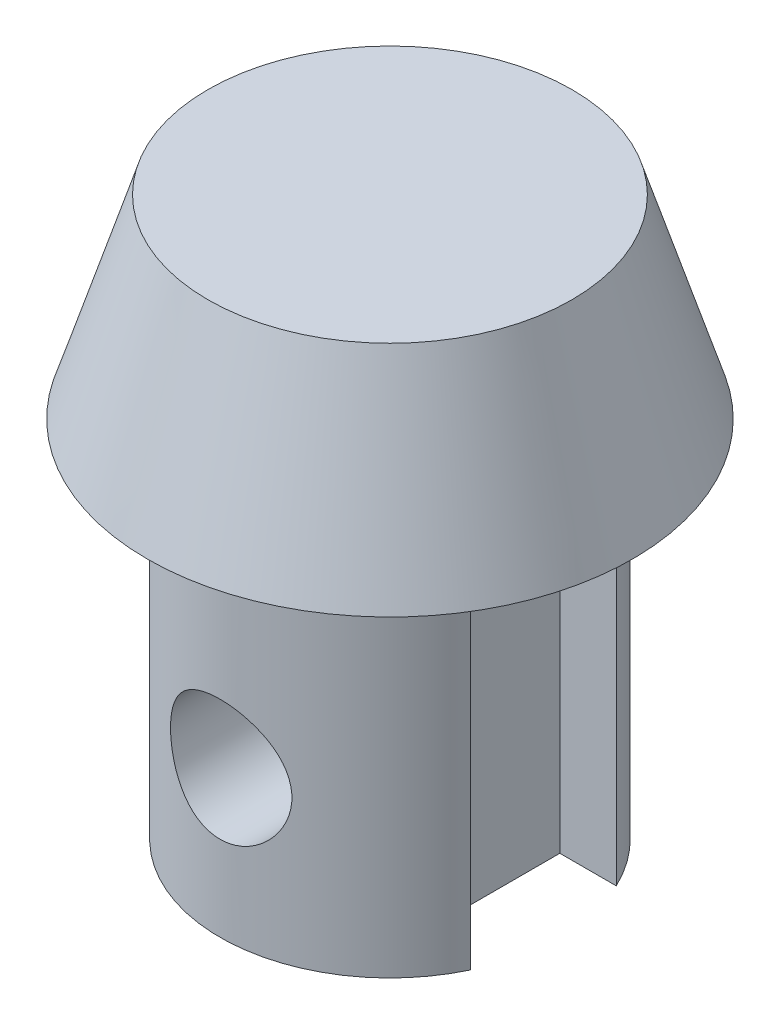
from build123d import *

# Parameters (mm, degrees)
BOSS_EXTRUDE1_DEPTH     = 15
SKETCH3_R               = 7.5
SKETCH2_R               = 10
SKETCH4_R               = 2.5
CUT_EXTRUDE1_DEPTH      = 22.0000001
CUT_EXTRUDE1_DEPTH_BACK = 1


with BuildPart() as part:
    # Sketch1 → Boss-Extrude1 (new body)
    with BuildSketch(Plane(origin=(0, 0, 0), x_dir=(1, 0, 0), z_dir=(0, 1, 0))):
        with BuildLine():
            Line((-6.32455532, -3), (-4, -3))
            Line((-4, -3), (-4, 3))
            Line((-4, 3), (-6.32455532, 3))
            ThreePointArc((-6.32455532, 3), (0, 7), (6.32455532, 3))
            Line((6.32455532, 3), (4, 3))
            Line((4, 3), (4, -3))
            Line((4, -3), (6.32455532, -3))
            ThreePointArc((6.32455532, -3), (0, -7), (-6.32455532, -3))
        make_face()
    extrude(amount=BOSS_EXTRUDE1_DEPTH)

    # Sketch3 → Loft1 section 0
    with BuildSketch(Plane(origin=(0, 23, 0), x_dir=(1, 0, 0), z_dir=(0, 1, 0))):
        Circle(SKETCH3_R)
    # Sketch2 → Loft1 section 1
    with BuildSketch(Plane(origin=(0, 15, 0), x_dir=(1, 0, 0), z_dir=(0, 1, 0))):
        Circle(SKETCH2_R)
    loft()

    # Sketch4 → Cut-Extrude1 (cut, two sides)
    with BuildSketch(Plane.XY.offset(-11)) as cut_extrude1_sk:
        with Locations((0, 6)):
            Circle(SKETCH4_R)
    extrude(amount=CUT_EXTRUDE1_DEPTH, mode=Mode.SUBTRACT)
    extrude(cut_extrude1_sk.sketch, amount=-CUT_EXTRUDE1_DEPTH_BACK, mode=Mode.SUBTRACT)


solid = part.part
